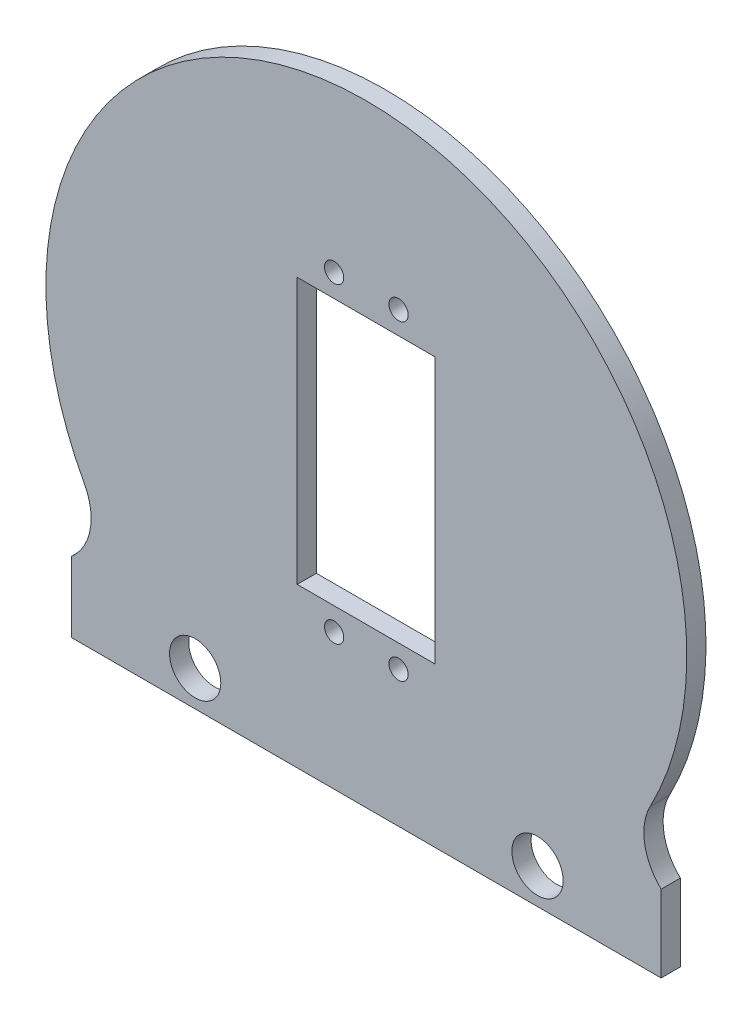
from build123d import *

# Parameters (mm, degrees)
SKETCH1_R           = 4
SKETCH1_R_2         = 1.5
SKETCH1_W           = 21.5
SKETCH1_H           = 41.5
BOSS_EXTRUDE1_DEPTH = 3


with BuildPart() as part:
    # Sketch1 → Boss-Extrude1 (new body)
    with BuildSketch(Plane.XY):
        with BuildLine():
            Line((-46, -34.546554859), (-46, -45.541019662))
            Line((-46, -45.541019662), (46, -45.541019662))
            Line((46, -45.541019662), (46, -33.541019662))
            ThreePointArc((46, -33.541019662), (43.418499553, -28.649357855), (44.29771076, -23.188635609))
            ThreePointArc((44.29771076, -23.188635609), (-0.32750764, 49.998927376), (-43.990137922, -23.766946914))
            ThreePointArc((-43.990137922, -23.766946914), (-43.089457574, -29.512052868), (-46, -34.546554859))
        make_face()
        with Locations((-26.71, -40.043787261)):
            Circle(SKETCH1_R, mode=Mode.SUBTRACT)
        with Locations((26.71, -40.043787261)):
            Circle(SKETCH1_R, mode=Mode.SUBTRACT)
        with Locations((5.025, -24.3)):
            Circle(SKETCH1_R_2, mode=Mode.SUBTRACT)
        with Locations((-5.025, -24.3)):
            Circle(SKETCH1_R_2, mode=Mode.SUBTRACT)
        with Locations((5.025, 24.3)):
            Circle(SKETCH1_R_2, mode=Mode.SUBTRACT)
        with Locations((-5.025, 24.3)):
            Circle(SKETCH1_R_2, mode=Mode.SUBTRACT)
        with Locations((-0.044828014, 0)):
            Rectangle(SKETCH1_W, SKETCH1_H, mode=Mode.SUBTRACT)
    extrude(amount=BOSS_EXTRUDE1_DEPTH)


solid = part.part
